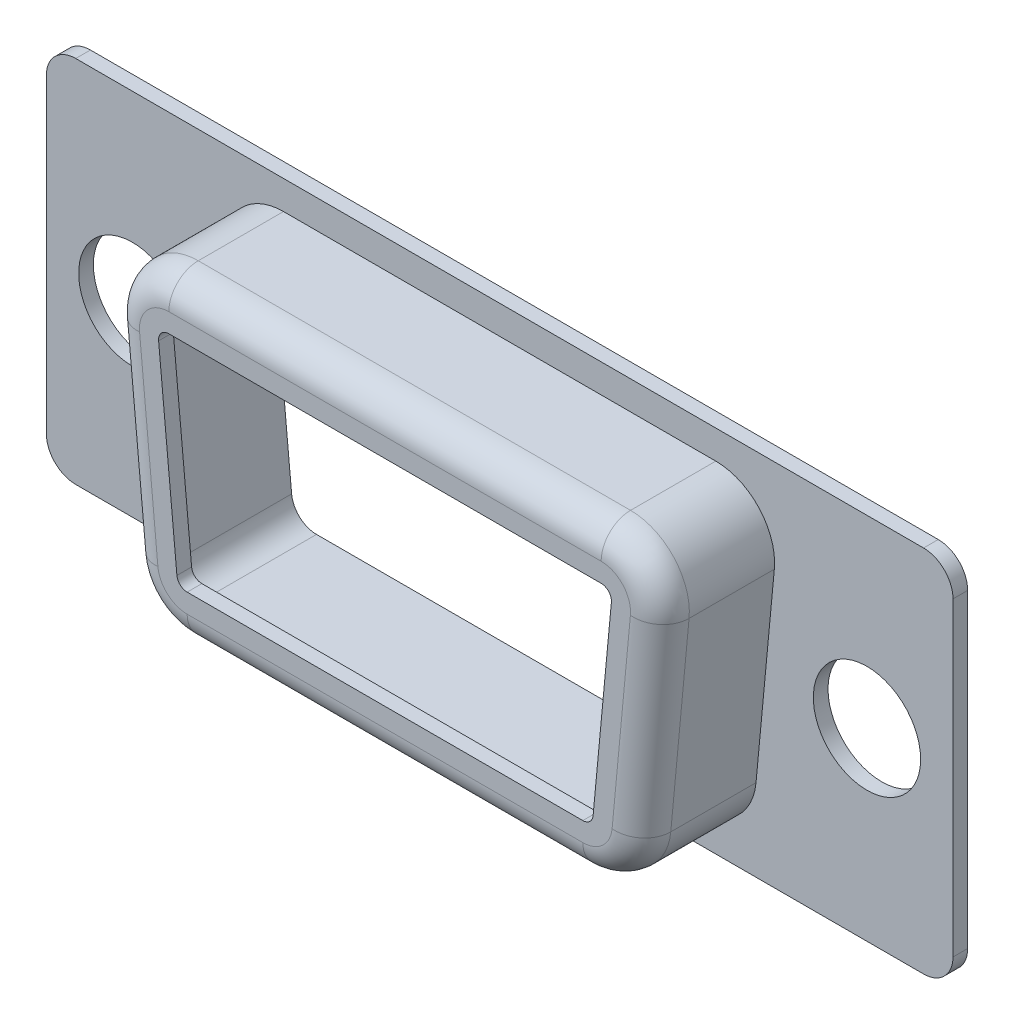
from build123d import *

# Parameters (mm, degrees)
BOSS_EXTRUDE1_DEPTH = 0.5
SKETCH2_R           = 1.825
CUT_EXTRUDE1_DEPTH  = 0.5
BOSS_EXTRUDE2_DEPTH = 3.9
CUT_EXTRUDE2_DEPTH  = 4.4
CUT_EXTRUDE3_DEPTH  = 3.9
FILLET1_R           = 1


with BuildPart() as part:
    # Sketch1 → Boss-Extrude1 (new body)
    with BuildSketch(Plane.XY):
        with BuildLine():
            Line((-14.42, 6.275), (14.42, 6.275))
            ThreePointArc((14.42, 6.275), (15.127106781, 5.982106781), (15.42, 5.275))
            Line((15.42, 5.275), (15.42, -5.275))
            ThreePointArc((15.42, -5.275), (15.127106781, -5.982106781), (14.42, -6.275))
            Line((14.42, -6.275), (-14.42, -6.275))
            ThreePointArc((-14.42, -6.275), (-15.127106781, -5.982106781), (-15.42, -5.275))
            Line((-15.42, -5.275), (-15.42, 5.275))
            ThreePointArc((-15.42, 5.275), (-15.127106781, 5.982106781), (-14.42, 6.275))
        make_face()
    extrude(amount=BOSS_EXTRUDE1_DEPTH)

    # Sketch2 → Cut-Extrude1 (cut)
    with BuildSketch(Plane.XY.offset(0.5)):
        with Locations((-12.495, 0)):
            Circle(SKETCH2_R)
        with Locations((12.495, 0)):
            Circle(SKETCH2_R)
    extrude(amount=-CUT_EXTRUDE1_DEPTH, mode=Mode.SUBTRACT)

    # Sketch3 → Boss-Extrude2 (add)
    with BuildSketch(Plane.XY.offset(0.5)):
        with BuildLine():
            Line((-7.352440505, 5.3), (7.352440505, 5.3))
            ThreePointArc((7.352440505, 5.3), (8.831577141, 4.646162996), (9.34359951, 3.112154811))
            Line((9.34359951, 3.112154811), (8.720958001, -3.487845189))
            ThreePointArc((8.720958001, -3.487845189), (8.075961991, -4.779136636), (6.729798996, -5.3))
            Line((6.729798996, -5.3), (-6.729798996, -5.3))
            ThreePointArc((-6.729798996, -5.3), (-8.075961991, -4.779136636), (-8.720958001, -3.487845189))
            Line((-8.720958001, -3.487845189), (-9.34359951, 3.112154811))
            ThreePointArc((-9.34359951, 3.112154811), (-8.831577141, 4.646162996), (-7.352440505, 5.3))
        make_face()
    extrude(amount=BOSS_EXTRUDE2_DEPTH)

    # Sketch4 → Cut-Extrude2 (cut)
    with BuildSketch(Plane.XY.offset(4.4)):
        with BuildLine():
            Line((7.078251822, -3.332872908), (7.700893331, 3.267127092))
            ThreePointArc((7.700893331, 3.267127092), (7.611289416, 3.535578524), (7.352440505, 3.65))
            Line((7.352440505, 3.65), (-7.352440505, 3.65))
            ThreePointArc((-7.352440505, 3.65), (-7.611289416, 3.535578524), (-7.700893331, 3.267127092))
            Line((-7.700893331, 3.267127092), (-7.078251822, -3.332872908))
            ThreePointArc((-7.078251822, -3.332872908), (-6.96537752, -3.558848911), (-6.729798996, -3.65))
            Line((-6.729798996, -3.65), (6.729798996, -3.65))
            ThreePointArc((6.729798996, -3.65), (6.96537752, -3.558848911), (7.078251822, -3.332872908))
        make_face()
    extrude(amount=-CUT_EXTRUDE2_DEPTH, mode=Mode.SUBTRACT)

    # Sketch5 → Cut-Extrude3 (cut)
    with BuildSketch(Plane.XY.offset(3.9)):
        with BuildLine():
            Line((7.352440505, 4.15), (-7.352440505, 4.15))
            ThreePointArc((-7.352440505, 4.15), (-7.981073576, 3.872119273), (-8.198683082, 3.220165795))
            Line((-8.198683082, 3.220165795), (-7.576041573, -3.379834205))
            ThreePointArc((-7.576041573, -3.379834205), (-7.301918269, -3.92863307), (-6.729798996, -4.15))
            Line((-6.729798996, -4.15), (6.729798996, -4.15))
            ThreePointArc((6.729798996, -4.15), (7.301918269, -3.92863307), (7.576041573, -3.379834205))
            Line((7.576041573, -3.379834205), (8.198683082, 3.220165795))
            ThreePointArc((8.198683082, 3.220165795), (7.981073576, 3.872119273), (7.352440505, 4.15))
        make_face()
        with BuildLine():
            Line((7.352440505, 3.65), (-7.352440505, 3.65))
            ThreePointArc((-7.352440505, 3.65), (-7.611289416, 3.535578524), (-7.700893331, 3.267127092))
            Line((-7.700893331, 3.267127092), (-7.078251822, -3.332872908))
            ThreePointArc((-7.078251822, -3.332872908), (-6.96537752, -3.558848911), (-6.729798996, -3.65))
            Line((-6.729798996, -3.65), (6.729798996, -3.65))
            ThreePointArc((6.729798996, -3.65), (6.96537752, -3.558848911), (7.078251822, -3.332872908))
            Line((7.078251822, -3.332872908), (7.700893331, 3.267127092))
            ThreePointArc((7.700893331, 3.267127092), (7.611289416, 3.535578524), (7.352440505, 3.65))
        make_face(mode=Mode.SUBTRACT)
    extrude(amount=-CUT_EXTRUDE3_DEPTH, mode=Mode.SUBTRACT)

    # Fillet1
    fillet1_edges = [part.edges().sort_by_distance(p)[0] for p in [
        (8.075961991, -4.779136636, 4.4),
        (9.032278756, -0.187845189, 4.4),
        (8.831577141, 4.646162996, 4.4),
        (0, 5.3, 4.4),
        (-8.831577141, 4.646162996, 4.4),
        (-9.032278756, -0.187845189, 4.4),
        (-8.075961991, -4.779136636, 4.4),
        (0, -5.3, 4.4),
    ]]
    fillet(fillet1_edges, radius=FILLET1_R)


solid = part.part
